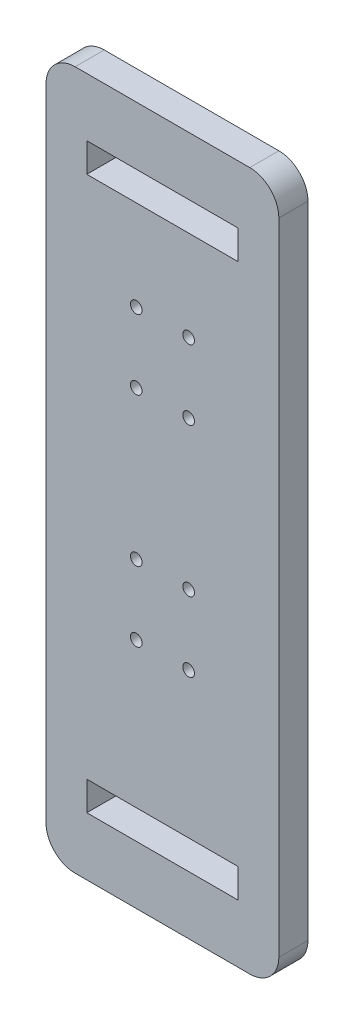
from build123d import *

# Parameters (mm, degrees)
SKETCH1_W           = 80
SKETCH1_H           = 240
BOSS_EXTRUDE1_DEPTH = 10
FILLET2_R           = 10
SKETCH2_R           = 2
SKETCH2_W           = 52
SKETCH2_H           = 10
CUT_EXTRUDE1_DEPTH  = 10


with BuildPart() as part:
    # Sketch1 → Boss-Extrude1 (new body)
    with BuildSketch(Plane.XY):
        with Locations((-40, 120)):
            Rectangle(SKETCH1_W, SKETCH1_H)
    extrude(amount=BOSS_EXTRUDE1_DEPTH)

    # Fillet2
    fillet2_edges = [part.edges().sort_by_distance(p)[0] for p in [
        (0, 0, 5),
        (-80, 0, 5),
        (-80, 240, 5),
        (0, 240, 5),
    ]]
    fillet(fillet2_edges, radius=FILLET2_R)

    # Sketch2 → Cut-Extrude1 (cut)
    with BuildSketch(Plane.XY.offset(10)):
        with Locations((-49, 154.94)):
            Circle(SKETCH2_R)
        with Locations((-31, 154.94)):
            Circle(SKETCH2_R)
        with Locations((-31, 178.94)):
            Circle(SKETCH2_R)
        with Locations((-49, 178.94)):
            Circle(SKETCH2_R)
        with Locations((-49, 103.94)):
            Circle(SKETCH2_R)
        with Locations((-49, 79.94)):
            Circle(SKETCH2_R)
        with Locations((-31, 103.94)):
            Circle(SKETCH2_R)
        with Locations((-31, 79.94)):
            Circle(SKETCH2_R)
        with Locations((-40, 215)):
            Rectangle(SKETCH2_W, SKETCH2_H)
        with Locations((-40, 25)):
            Rectangle(SKETCH2_W, SKETCH2_H)
    extrude(amount=-CUT_EXTRUDE1_DEPTH, mode=Mode.SUBTRACT)


solid = part.part
